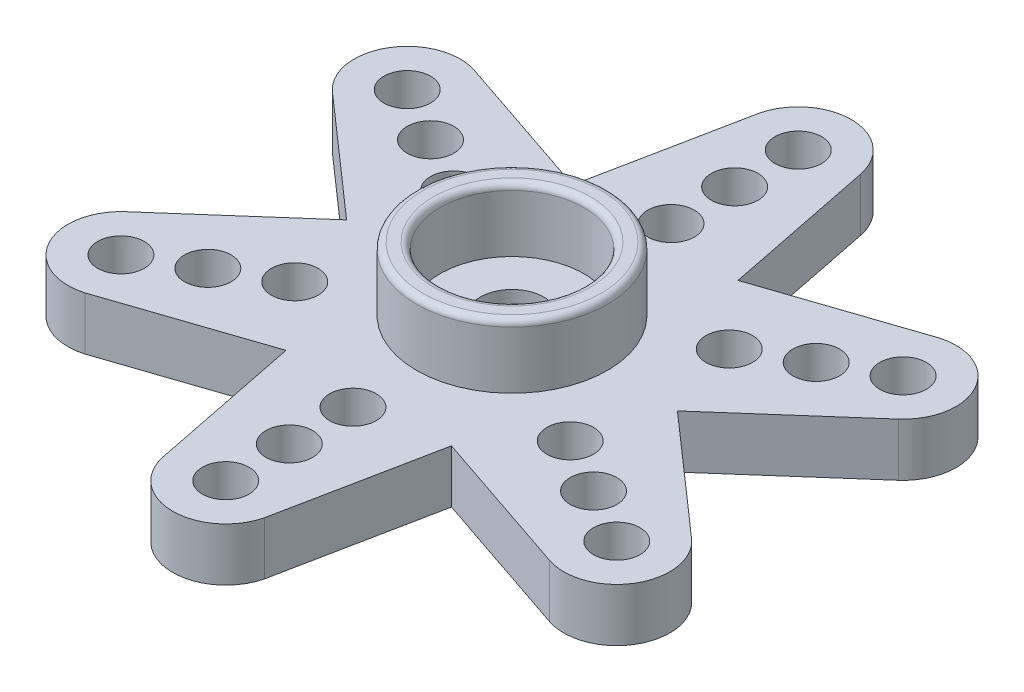
from build123d import *

# Parameters (mm, degrees)
SALIENTE_EXTRUIR1_DEPTH = 2.5
CROQUIS2_R              = 4.5
CROQUIS2_R_2            = 3.4
SALIENTE_EXTRUIR2_DEPTH = 3
CORTAR_EXTRUIR1_REACH   = 7.5
CROQUIS3_R              = 1.5
CROQUIS4_R              = 2.8
CORTAR_EXTRUIR2_DEPTH   = 1
CROQUIS5_R              = 4.5
CROQUIS5_R_2            = 3.5
CORTAR_EXTRUIR3_DEPTH   = 0.5
REDONDEO1_R             = 0.3
CROQUIS6_R              = 1.1
CORTAR_EXTRUIR4_DEPTH   = 2.5
MATRIZC1_COUNT          = 6


with BuildPart() as part:
    # Croquis1 → Saliente-Extruir1 (new body)
    with BuildSketch(Plane(origin=(0, 0, 0), x_dir=(1, 0, 0), z_dir=(0, 1, 0))):
        with BuildLine():
            Line((-3.9, -6.75499815), (-10.994862545, -9.151023749))
            ThreePointArc((-10.994862545, -9.151023749), (-13.88318634, -7.952423618), (-13.342044439, -4.872452504))
            Line((-13.342044439, -4.872452504), (-7.8, 0))
            Line((-7.8, 0), (-13.42245031, 4.9463184))
            ThreePointArc((-13.42245031, 4.9463184), (-13.828594045, 8.046980247), (-10.890689867, 9.11832317))
            Line((-10.890689867, 9.11832317), (-3.9, 6.75499815))
            Line((-3.9, 6.75499815), (-2.427587765, 14.097342149))
            ThreePointArc((-2.427587765, 14.097342149), (0.054592295, 15.999403865), (2.451354572, 13.990775674))
            Line((2.451354572, 13.990775674), (3.9, 6.75499815))
            Line((3.9, 6.75499815), (10.994862545, 9.151023749))
            ThreePointArc((10.994862545, 9.151023749), (13.88318634, 7.952423618), (13.342044439, 4.872452504))
            Line((13.342044439, 4.872452504), (7.8, 0))
            Line((7.8, 0), (13.42245031, -4.9463184))
            ThreePointArc((13.42245031, -4.9463184), (13.828594045, -8.046980247), (10.890689867, -9.11832317))
            Line((10.890689867, -9.11832317), (3.9, -6.75499815))
            Line((3.9, -6.75499815), (2.427587765, -14.097342149))
            ThreePointArc((2.427587765, -14.097342149), (-0.054592295, -15.999403865), (-2.451354572, -13.990775674))
            Line((-2.451354572, -13.990775674), (-3.9, -6.75499815))
        make_face()
    extrude(amount=SALIENTE_EXTRUIR1_DEPTH)

    # Croquis2 → Saliente-Extruir2 (add)
    with BuildSketch(Plane(origin=(0, 2.5, 0), x_dir=(1, 0, 0), z_dir=(0, 1, 0))):
        Circle(CROQUIS2_R)
        Circle(CROQUIS2_R_2, mode=Mode.SUBTRACT)
    extrude(amount=SALIENTE_EXTRUIR2_DEPTH)

    # Croquis3 → Cortar-Extruir1 (cut, up to next)
    with BuildSketch(Plane.XZ, mode=Mode.PRIVATE) as cortar_extruir1_sk1:
        Circle(CROQUIS3_R)
    cortar_extruir1_tool1 = extrude(cortar_extruir1_sk1.sketch, amount=-CORTAR_EXTRUIR1_REACH, mode=Mode.PRIVATE) & part.part
    add(cortar_extruir1_tool1.solids().sort_by_distance((0, 0, 0))[0], mode=Mode.SUBTRACT)

    # Croquis4 → Cortar-Extruir2 (cut)
    with BuildSketch(Plane.XZ):
        Circle(CROQUIS4_R)
    extrude(amount=-CORTAR_EXTRUIR2_DEPTH, mode=Mode.SUBTRACT)

    # Croquis5 → Cortar-Extruir3 (cut)
    with BuildSketch(Plane.XZ):
        Circle(CROQUIS5_R)
        Circle(CROQUIS5_R_2, mode=Mode.SUBTRACT)
    extrude(amount=-CORTAR_EXTRUIR3_DEPTH, mode=Mode.SUBTRACT)

    # Redondeo1
    redondeo1_edges = [part.edges().sort_by_distance(p)[0] for p in [
        (-4.5, 5.5, 0),
        (-3.4, 5.5, 0),
        (-2.8, 0, 0),
        (-4.5, 0, 0),
        (-3.5, 0, 0),
    ]]
    fillet(redondeo1_edges, radius=REDONDEO1_R)

    # Croquis6 → Cortar-Extruir4 (cut)
    with BuildSketch(Plane.XZ):
        with Locations((0, -13.5)):
            Circle(CROQUIS6_R)
        with Locations((0, -10.5)):
            Circle(CROQUIS6_R)
        with Locations((0, -7.5)):
            Circle(CROQUIS6_R)
    cortar_extruir4 = extrude(amount=-CORTAR_EXTRUIR4_DEPTH, mode=Mode.SUBTRACT)

    # MatrizC1: Cortar-Extruir4 ×6 about axis
    matrizc1_axis = Axis((0, 0, 0), (0, 1, 0))
    for i in range(1, MATRIZC1_COUNT):
        add(cortar_extruir4.rotate(matrizc1_axis, i * 360 / MATRIZC1_COUNT), mode=Mode.SUBTRACT)


solid = part.part
